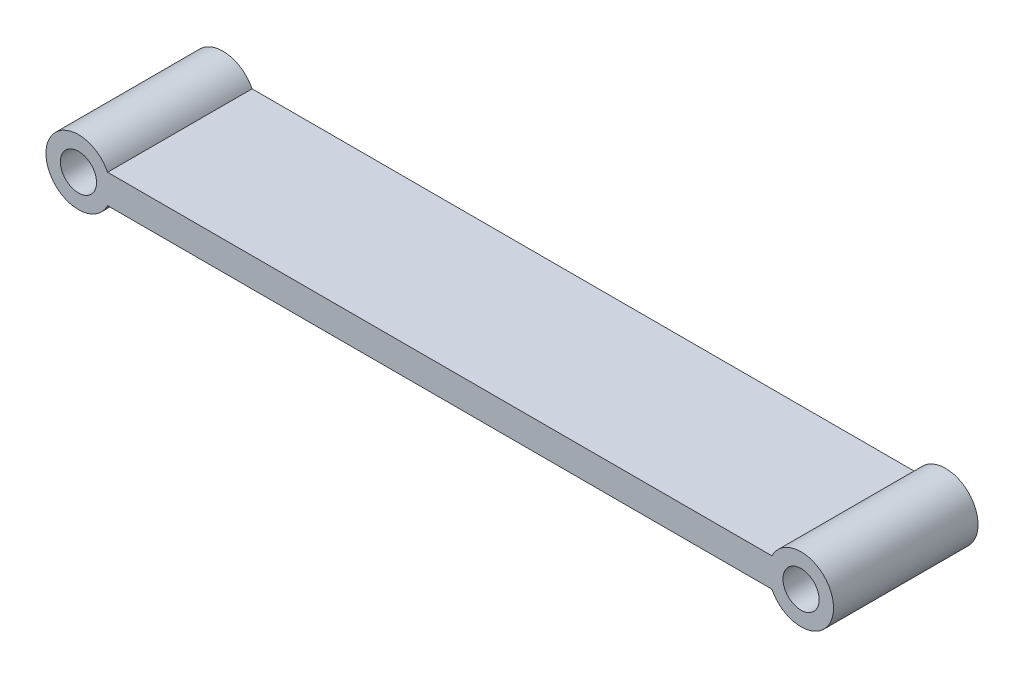
from build123d import *

# Parameters (mm, degrees)
SKETCH1_R           = 3.175
BOSS_EXTRUDE1_DEPTH = 12.7


with BuildPart() as part:
    # Sketch1 → Boss-Extrude1 (new body, symmetric)
    with BuildSketch(Plane.XY):
        with BuildLine():
            Line((5.11953367, 2.54), (121.88046633, 2.54))
            ThreePointArc((121.88046633, 2.54), (132.715, 0), (121.88046633, -2.54))
            Line((121.88046633, -2.54), (5.11953367, -2.54))
            ThreePointArc((5.11953367, -2.54), (-5.715, 0), (5.11953367, 2.54))
        make_face()
        Circle(SKETCH1_R, mode=Mode.SUBTRACT)
        with Locations((127, 0)):
            Circle(SKETCH1_R, mode=Mode.SUBTRACT)
    extrude(amount=BOSS_EXTRUDE1_DEPTH, both=True)


solid = part.part
